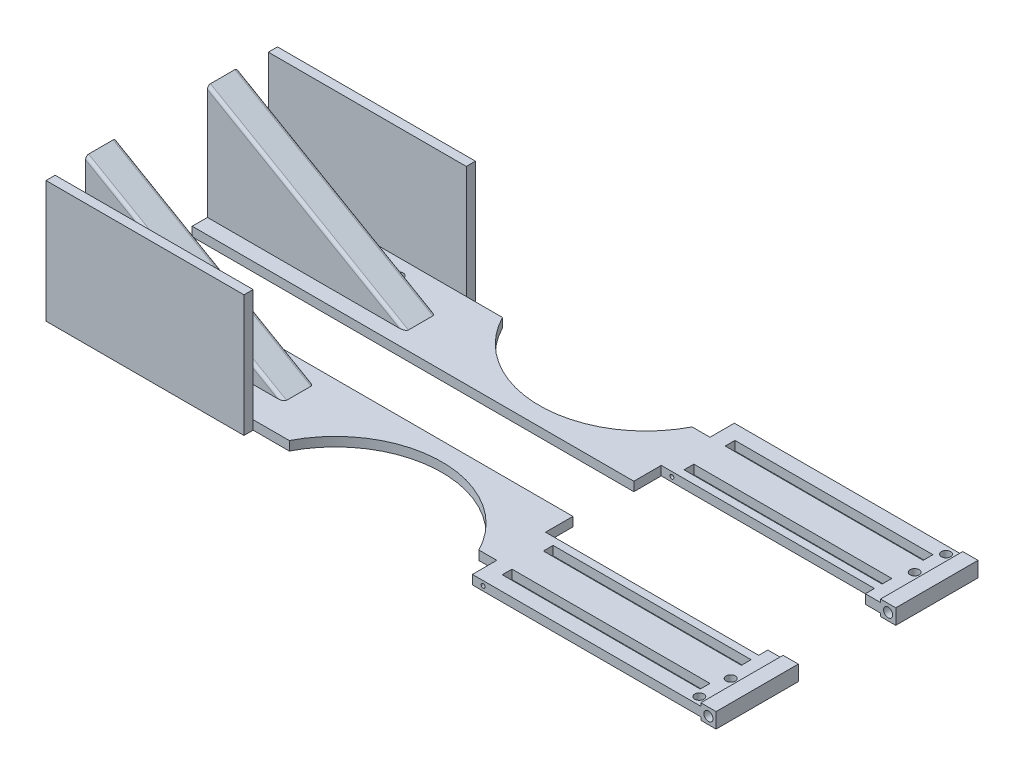
from build123d import *

# Parameters (mm, degrees)
SKETCH_1_W               = 220
SKETCH_1_H               = 70
EXTRUDE_1_DEPTH          = 3
EXTRUDE_2_DEPTH          = 25
EXTRUDE_2_DEPTH_BACK     = 25
SKETCH_6_W               = 30
SKETCH_6_H               = 37.527767497
CUT_EXTRUDE_4_DEPTH      = 221
SKETCH_7_R               = 35
CUT_EXTRUDE_5_DEPTH      = 4
SKETCH_8_W               = 3
SKETCH_8_H               = 40
EXTRUDE_3_DEPTH          = 65
SKETCH_9_R               = 1.5
CUT_EXTRUDE_6_DEPTH      = 4
FILLET_5_R               = 1
SKETCH_10_W              = 65
SKETCH_10_H              = 20
CUT_EXTRUDE_7_DEPTH      = 4
EXTRUDE_4283_DEPTH       = 3
SKETCH_12_W              = 65
SKETCH_12_H              = 3.2
CUT_EXTRUDE_4965_DEPTH   = 3
CUT_EXTRUDE_9_DEPTH      = 38.527767497
CUT_EXTRUDE_9_DEPTH_BACK = 3
SKETCH_14_R              = 0.65
CUT_EXTRUDE_10_DEPTH     = 87
SKETCH_17_W              = 27
SKETCH_17_H              = 5
EXTRUDE_4_DEPTH          = 5
SKETCH_19_R              = 1.5
CUT_EXTRUDE_11_DEPTH     = 87
SKETCH_20_R              = 1.5
CUT_EXTRUDE_12_DEPTH     = 5
SKETCH_21_W              = 80
SKETCH_21_H              = 20
CUT_EXTRUDE_15_DEPTH     = 10


with BuildPart() as part:
    # 草图1 → 凸台-拉伸1 (new body)
    with BuildSketch(Plane(origin=(0, 0, 0), x_dir=(1, 0, 0), z_dir=(0, 1, 0))):
        with Locations((27.295373665, 0)):
            Rectangle(SKETCH_1_W, SKETCH_1_H)
    extrude(amount=EXTRUDE_1_DEPTH)

    # 草图2 → 凸台-拉伸2 (add, two sides)
    with BuildSketch(Plane.XY) as extrude_2_sk:
        Polygon((-82.704626335, 40.527767497), (-82.704626335, 3), (-17.704626335, 3), align=None)
    extrude(amount=EXTRUDE_2_DEPTH)
    extrude(extrude_2_sk.sketch, amount=-EXTRUDE_2_DEPTH_BACK)

    # 草图6 → 切除-拉伸4 (cut, through all)
    with BuildSketch(Plane.ZY.offset(82.704626335)):
        with Locations((0, 21.763883748)):
            Rectangle(SKETCH_6_W, SKETCH_6_H)
    extrude(amount=-CUT_EXTRUDE_4_DEPTH, mode=Mode.SUBTRACT)

    # 草图7 → 切除-拉伸5 (cut, through all)
    with BuildSketch(Plane(origin=(0, 3, 0), x_dir=(1, 0, 0), z_dir=(0, 1, 0))):
        with Locations((25.295373665, 51)):
            Circle(SKETCH_7_R)
        with Locations((25.295373665, -51)):
            Circle(SKETCH_7_R)
    extrude(amount=-CUT_EXTRUDE_5_DEPTH, mode=Mode.SUBTRACT)

    # 草图8 → 凸台-拉伸3 (add)
    with BuildSketch(Plane.ZY.offset(82.704626335)):
        with Locations((36.5, 20)):
            Rectangle(SKETCH_8_W, SKETCH_8_H)
        with Locations((-36.5, 20)):
            Rectangle(SKETCH_8_W, SKETCH_8_H)
    extrude(amount=-EXTRUDE_3_DEPTH)

    # 草图9 → 切除-拉伸6 (cut, through all)
    with BuildSketch(Plane(origin=(0, 3, 0), x_dir=(1, 0, 0), z_dir=(0, 1, 0))):
        with Locations((-74.766784803, 29.860059225)):
            Circle(SKETCH_9_R)
        with Locations((-54.766784803, 29.860059225)):
            Circle(SKETCH_9_R)
        with Locations((-34.766784803, 29.860059225)):
            Circle(SKETCH_9_R)
        with Locations((-34.766784803, -29.860059225)):
            Circle(SKETCH_9_R)
        with Locations((-54.766784803, -29.860059225)):
            Circle(SKETCH_9_R)
        with Locations((-74.766784803, -29.860059225)):
            Circle(SKETCH_9_R)
    extrude(amount=-CUT_EXTRUDE_6_DEPTH, mode=Mode.SUBTRACT)

    # 圆角5
    fillet_5_edges = [part.edges().sort_by_distance(p)[0] for p in [
        (-50.204626335, 21.763883749, -25),
        (-50.204626335, 21.763883749, 25),
        (-50.204626335, 21.763883749, -15),
        (-50.204626335, 21.763883749, 15),
    ]]
    fillet(fillet_5_edges, radius=FILLET_5_R)

    # 草图10 → 切除-拉伸7 (cut, through all)
    with BuildSketch(Plane(origin=(0, 3, 0), x_dir=(1, 0, 0), z_dir=(0, 1, 0))):
        with Locations((-50.204626335, 0)):
            Rectangle(SKETCH_10_W, SKETCH_10_H)
    extrude(amount=-CUT_EXTRUDE_7_DEPTH, mode=Mode.SUBTRACT)

    # 草图11 → Extrude 4283 (add)
    with BuildSketch(Plane(origin=(0, 3, 0), x_dir=(1, 0, 0), z_dir=(0, 1, 0))):
        Polygon((132.295373665, 35), (137.295373665, 35), (137.295373665, 43), (62.295373665, 43), (62.295373665, 35), (67.295373665, 35), (67.295373665, 38.2), (132.295373665, 38.2), align=None)
        Polygon((137.295373665, -43), (137.295373665, -35), (132.295373665, -35), (132.295373665, -38.2), (67.295373665, -38.2), (67.295373665, -35), (62.295373665, -35), (62.295373665, -43), align=None)
    extrude(amount=-EXTRUDE_4283_DEPTH)

    # 草图12 → Cut-Extrude 4965 (cut)
    with BuildSketch(Plane(origin=(0, 3, 0), x_dir=(1, 0, 0), z_dir=(0, 1, 0))):
        with Locations((99.795373665, -23.1)):
            Rectangle(SKETCH_12_W, SKETCH_12_H)
        with Locations((99.795373665, 23.1)):
            Rectangle(SKETCH_12_W, SKETCH_12_H)
    extrude(amount=-CUT_EXTRUDE_4965_DEPTH, mode=Mode.SUBTRACT)

    # 草图13 → 切除-拉伸9 (cut, two sides)
    with BuildSketch(Plane(origin=(0, 3, 0), x_dir=(1, 0, 0), z_dir=(0, 1, 0))) as cut_extrude_9_sk:
        Polygon((62.295373665, 19), (62.295373665, -19), (132.295373665, -19), (132.295373665, -16), (137.295373665, -16), (137.295373665, 0), (137.295373665, 16), (132.295373665, 16), (132.295373665, 19), align=None)
    extrude(amount=CUT_EXTRUDE_9_DEPTH, mode=Mode.SUBTRACT)
    extrude(cut_extrude_9_sk.sketch, amount=-CUT_EXTRUDE_9_DEPTH_BACK, mode=Mode.SUBTRACT)

    # 草图14 → 切除-拉伸10 (cut, through all)
    with BuildSketch(Plane.XY.offset(43)):
        with Locations((65.795373665, 1.5)):
            Circle(SKETCH_14_R)
    extrude(amount=-CUT_EXTRUDE_10_DEPTH, mode=Mode.SUBTRACT)

    # 草图17 → 凸台-拉伸4 (add)
    with BuildSketch(Plane(origin=(137.295373665, 0, 0), x_dir=(0, 0, -1), z_dir=(1, 0, 0))):
        with Locations((29.5, 1.5)):
            Rectangle(SKETCH_17_W, SKETCH_17_H)
        with Locations((-29.5, 1.5)):
            Rectangle(SKETCH_17_W, SKETCH_17_H)
    extrude(amount=EXTRUDE_4_DEPTH)

    # 草图19 → 切除-拉伸11 (cut, through all)
    with BuildSketch(Plane(origin=(0, 0, -43), x_dir=(-1, 0, 0), z_dir=(0, 0, -1))):
        with Locations((-139.795373665, 1.435601605)):
            Circle(SKETCH_19_R)
    extrude(amount=-CUT_EXTRUDE_11_DEPTH, mode=Mode.SUBTRACT)

    # 草图20 → 切除-拉伸12 (cut, through all)
    with BuildSketch(Plane(origin=(0, 3, 0), x_dir=(1, 0, 0), z_dir=(0, 1, 0))):
        with Locations((134.295373665, 30.202873248)):
            Circle(SKETCH_20_R)
        with Locations((134.295373665, -30.202873248)):
            Circle(SKETCH_20_R)
        with Locations((134.295373665, 40.5)):
            Circle(SKETCH_20_R)
        with Locations((134.295373665, -40.5)):
            Circle(SKETCH_20_R)
    extrude(amount=-CUT_EXTRUDE_12_DEPTH, mode=Mode.SUBTRACT)

    # 草图21 → 切除-拉伸15 (cut)
    with BuildSketch(Plane(origin=(0, 3, 0), x_dir=(1, 0, 0), z_dir=(0, 1, 0))):
        with Locations((22.295373665, 0)):
            Rectangle(SKETCH_21_W, SKETCH_21_H)
    extrude(amount=-CUT_EXTRUDE_15_DEPTH, mode=Mode.SUBTRACT)


solid = part.part
